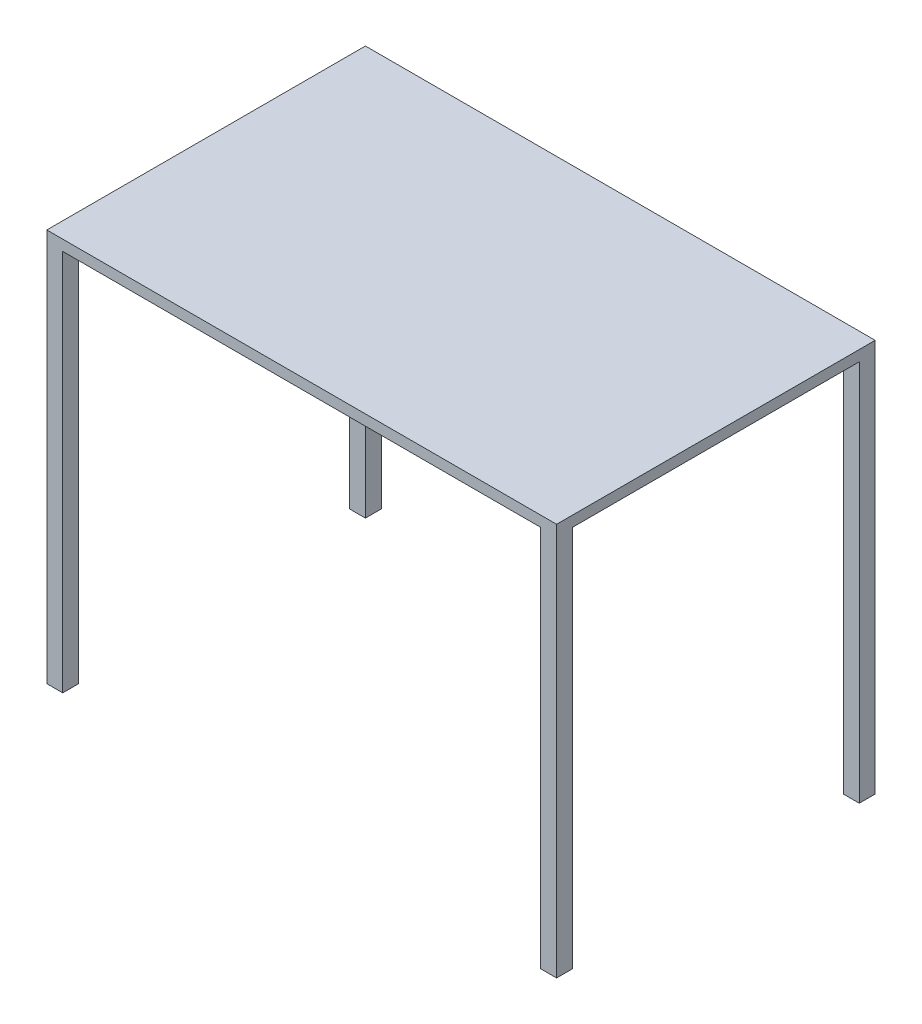
from build123d import *

# Parameters (mm, degrees)
SKETCH1_W           = 1219.2
SKETCH1_H           = 762
BOSS_EXTRUDE1_DEPTH = 25.4
SKETCH3_W           = 38.1
SKETCH3_H           = 38.1
BOSS_EXTRUDE2_DEPTH = 914.4


with BuildPart() as part:
    # Sketch1 → Boss-Extrude1 (new body)
    with BuildSketch(Plane(origin=(0, 0, 0), x_dir=(1, 0, 0), z_dir=(0, 1, 0))):
        Rectangle(SKETCH1_W, SKETCH1_H)
    extrude(amount=BOSS_EXTRUDE1_DEPTH)

    # Sketch3 → Boss-Extrude2 (add)
    with BuildSketch(Plane.XZ):
        with Locations((-590.55, 361.95)):
            Rectangle(SKETCH3_W, SKETCH3_H)
        with Locations((590.55, 361.95)):
            Rectangle(SKETCH3_W, SKETCH3_H)
        with Locations((590.55, -361.95)):
            Rectangle(SKETCH3_W, SKETCH3_H)
        with Locations((-590.55, -361.95)):
            Rectangle(SKETCH3_W, SKETCH3_H)
    extrude(amount=BOSS_EXTRUDE2_DEPTH)


solid = part.part
